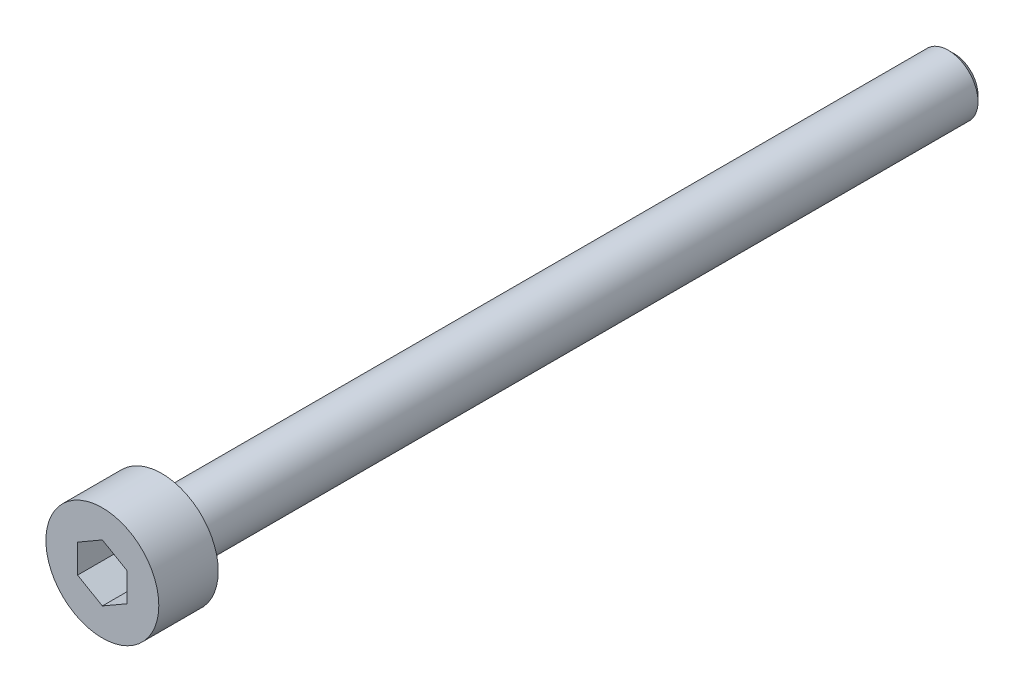
from build123d import *

# Parameters (mm, degrees)
SKETCH1_R           = 2.85
BOSS_EXTRUDE1_DEPTH = 3
SKETCH2_R           = 1.5
BOSS_EXTRUDE2_DEPTH = 40
CHAMFER1_SIZE       = 0.3
CUT_EXTRUDE1_DEPTH  = 2


with BuildPart() as part:
    # Sketch1 → Boss-Extrude1 (new body)
    with BuildSketch(Plane.XY):
        Circle(SKETCH1_R)
    extrude(amount=BOSS_EXTRUDE1_DEPTH)

    # Sketch2 → Boss-Extrude2 (add)
    with BuildSketch(Plane(origin=(0, 0, 0), x_dir=(-1, 0, 0), z_dir=(0, 0, -1))):
        Circle(SKETCH2_R)
    extrude(amount=BOSS_EXTRUDE2_DEPTH)

    # Chamfer1
    chamfer1_edges = [part.edges().sort_by_distance(p)[0] for p in [
        (1.5, 0, -40),
    ]]
    chamfer(chamfer1_edges, length=CHAMFER1_SIZE)

    # Sketch3 → Cut-Extrude1 (cut)
    with BuildSketch(Plane.XY.offset(3)):
        Polygon((0, 1.443375673), (-1.25, 0.721687836), (-1.25, -0.721687836), (0, -1.443375673), (1.25, -0.721687836), (1.25, 0.721687836), align=None)
    extrude(amount=-CUT_EXTRUDE1_DEPTH, mode=Mode.SUBTRACT)


solid = part.part
